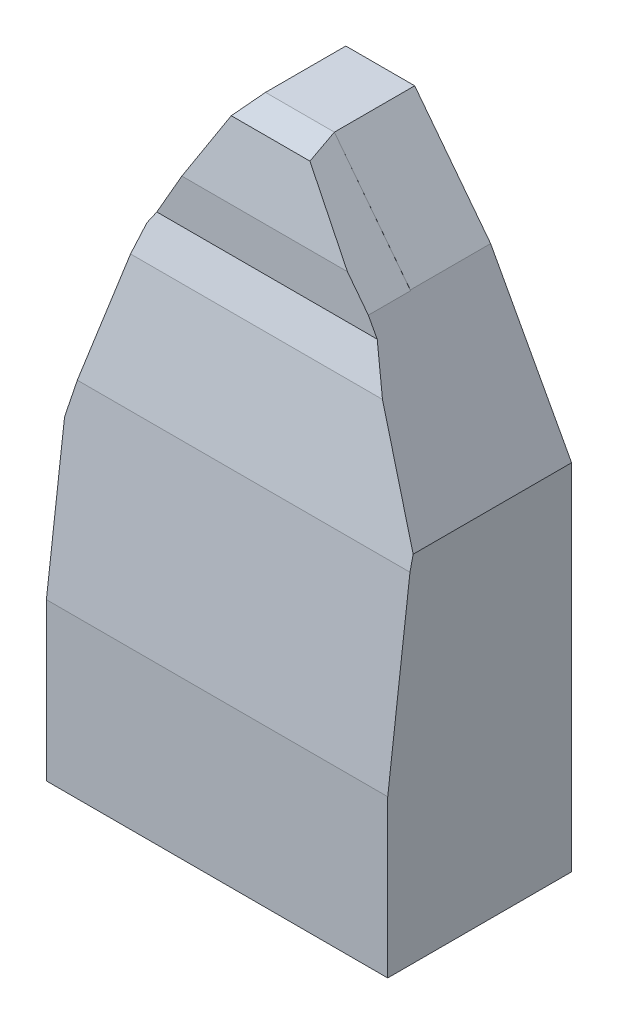
from build123d import *

# Parameters (mm, degrees)
BOSS_EXTRUDE1_DEPTH = 101.6
BOSS_EXTRUDE2_DEPTH = 431.8
CUT_EXTRUDE1_DEPTH  = 132.021743181
CUT_EXTRUDE2_DEPTH  = 132.021743181
SKETCH5_W           = 672.515990181
SKETCH5_H           = 895.069856367
CUT_EXTRUDE3_DEPTH  = 233.621743181


with BuildPart() as part:
    # Sketch1 → Boss-Extrude1 (new body)
    with BuildSketch(Plane.XY):
        Polygon((0, 0), (431.8, 0), (431.8, 387.403361345), (377.065490396, 602.774956458), (285.641844577, 762), (198.504201681, 762), (102.453781513, 637.134453782), (0, 448.235294118), align=None)
    boss_extrude1 = extrude(amount=BOSS_EXTRUDE1_DEPTH)

    # Sketch2 → Boss-Extrude2 (add)
    with BuildSketch(Plane.ZY):
        Polygon((101.6, 0), (232.621743181, 0), (232.621743181, 198.64821401), (204.451845393, 430.506603568), (172.780455352, 570.81191653), (155.089264466, 615.704741573), (155.089264466, 670.908278379), (139.607943989, 752.787376516), (101.6, 762), align=None)
    boss_extrude2 = extrude(amount=-BOSS_EXTRUDE2_DEPTH)

    # Sketch3 → Cut-Extrude1 (cut, through all)
    with BuildSketch(Plane(origin=(0, 0, 101.6), x_dir=(-1, 0, 0), z_dir=(0, 0, -1))):
        Polygon((0, 448.235294118), (-102.079559314, 636.444481603), (-205.052343037, 770.512583763), (-205.052343037, 987.342816442), (227.879484492, 941.92173413), (179.71587047, 482.849418415), align=None)
    cut_extrude1 = extrude(amount=-CUT_EXTRUDE1_DEPTH, mode=Mode.SUBTRACT)

    # Sketch4 → Cut-Extrude2 (cut, through all)
    with BuildSketch(Plane(origin=(0, 0, 101.6), x_dir=(-1, 0, 0), z_dir=(0, 0, -1))):
        Polygon((-431.8, 387.403361345), (-377.065490396, 602.774956458), (-285.641844577, 762), (-386.647779508, 961.526140846), (-935.090979015, 961.526140846), (-884.913915701, 472.949119069), align=None)
    cut_extrude2 = extrude(amount=-CUT_EXTRUDE2_DEPTH, mode=Mode.SUBTRACT)

    # Mirror1: Boss-Extrude1, Boss-Extrude2, Cut-Extrude1, Cut-Extrude2 across plane
    add(boss_extrude1.mirror(Plane(origin=(0, 0, 0), x_dir=(0, 0, 1), z_dir=(1, 0, 0))))
    add(boss_extrude2.mirror(Plane(origin=(0, 0, 0), x_dir=(0, 0, 1), z_dir=(1, 0, 0))))
    add(cut_extrude1.mirror(Plane(origin=(0, 0, 0), x_dir=(0, 0, 1), z_dir=(1, 0, 0))), mode=Mode.SUBTRACT)
    add(cut_extrude2.mirror(Plane(origin=(0, 0, 0), x_dir=(0, 0, 1), z_dir=(1, 0, 0))), mode=Mode.SUBTRACT)

    # Sketch5 → Cut-Extrude3 (cut, through all)
    with BuildSketch(Plane.XY):
        with Locations((336.257995091, 447.534928184)):
            Rectangle(SKETCH5_W, SKETCH5_H)
    extrude(amount=CUT_EXTRUDE3_DEPTH, mode=Mode.SUBTRACT)


solid = part.part
